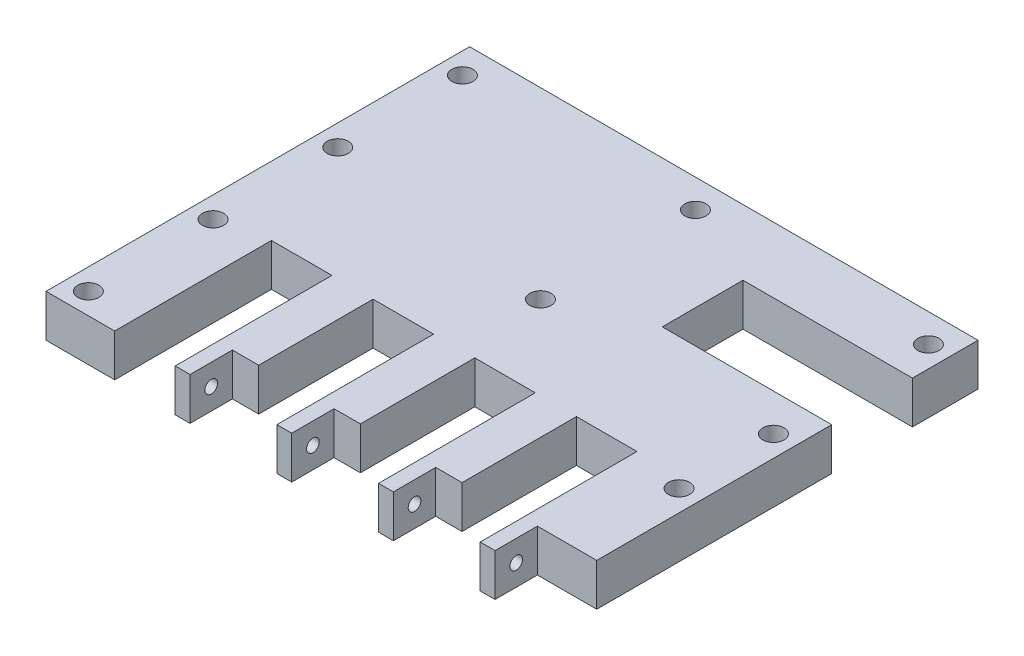
from build123d import *

# Parameters (mm, degrees)
SKETCH1_W                 = 120
SKETCH1_H                 = 100
BOSS_EXTRUDE1_DEPTH       = 10
CUT_EXTRUDE1_DEPTH        = 37
SKETCH3_W                 = 6.2125
SKETCH3_H                 = 10
SKETCH3_W_2               = 14
CUT_EXTRUDE2_DEPTH        = 10
SKETCH4_R                 = 1.5
CUT_EXTRUDE3_DEPTH        = 75.5
SKETCH7_R                 = 2.5
SKETCH7_W                 = 40
SKETCH7_H                 = 19.05
CUT_EXTRUDE4_DEPTH        = 20
SKETCH10_R                = 2.5
CUT_EXTRUDE5_DEPTH        = 10
F_5_0MM_DOWEL_HOLE1_D     = 5
F_5_0MM_DOWEL_HOLE1_DEPTH = 25
F_5_0MM_DOWEL_HOLE1_TIP   = 1.502151548


with BuildPart() as part:
    # Sketch1 → Boss-Extrude1 (new body)
    with BuildSketch(Plane(origin=(0, 0, 0), x_dir=(1, 0, 0), z_dir=(0, 1, 0))):
        Rectangle(SKETCH1_W, SKETCH1_H)
    extrude(amount=BOSS_EXTRUDE1_DEPTH)

    # Sketch2 → Cut-Extrude1 (cut)
    with BuildSketch(Plane.XY.offset(50)):
        Polygon((-42.5, 10), (-43.7875, 10), (-43.7875, -10), (-42.5, -10), (-29.5, -10), (-29.5, 10), align=None)
        Polygon((-5.5, -10), (-18.5, -10), (-19.7875, -10), (-19.7875, 10), (-18.5, 10), (-5.5, 10), align=None)
        Polygon((18.5, -10), (5.5, -10), (4.2125, -10), (4.2125, 10), (5.5, 10), (18.5, 10), align=None)
        Polygon((42.5, -10), (29.5, -10), (28.2125, -10), (28.2125, 10), (29.5, 10), (42.5, 10), align=None)
    extrude(amount=-CUT_EXTRUDE1_DEPTH, mode=Mode.SUBTRACT)

    # Sketch3 → Cut-Extrude2 (cut)
    with BuildSketch(Plane.XY.offset(50)):
        with Locations((-22.89375, 5)):
            Rectangle(SKETCH3_W, SKETCH3_H)
        with Locations((1.10625, 5)):
            Rectangle(SKETCH3_W, SKETCH3_H)
        with Locations((25.10625, 5)):
            Rectangle(SKETCH3_W, SKETCH3_H)
        with Locations((53, 5)):
            Rectangle(SKETCH3_W_2, SKETCH3_H)
    extrude(amount=-CUT_EXTRUDE2_DEPTH, mode=Mode.SUBTRACT)

    # Sketch4 → Cut-Extrude3 (cut)
    with BuildSketch(Plane(origin=(46, 0, 0), x_dir=(0, 0, -1), z_dir=(1, 0, 0))):
        with Locations((-45, 5)):
            Circle(SKETCH4_R)
    extrude(amount=-CUT_EXTRUDE3_DEPTH, mode=Mode.SUBTRACT)

    # Sketch7 → Cut-Extrude4 (cut)
    with BuildSketch(Plane(origin=(0, 10, 0), x_dir=(1, 0, 0), z_dir=(0, 1, 0))):
        with Locations((55, 6.7125)):
            Circle(SKETCH7_R)
        with Locations((55, 43.2875)):
            Circle(SKETCH7_R)
        with Locations((0, 43.2875)):
            Circle(SKETCH7_R)
        with Locations((0, 6.7125)):
            Circle(SKETCH7_R)
        with Locations((40, 25)):
            Rectangle(SKETCH7_W, SKETCH7_H)
    extrude(amount=-CUT_EXTRUDE4_DEPTH, mode=Mode.SUBTRACT)

    # Sketch10 → Cut-Extrude5 (cut)
    with BuildSketch(Plane(origin=(0, 10, 0), x_dir=(1, 0, 0), z_dir=(0, 1, 0))):
        with Locations((-55, 43.2875)):
            Circle(SKETCH10_R)
        with Locations((55, 43.2875)):
            Circle(SKETCH10_R)
        with Locations((55, 6.7125)):
            Circle(SKETCH10_R)
        with Locations((-55, 13.858333333)):
            Circle(SKETCH10_R)
        with Locations((-55, -15.570833333)):
            Circle(SKETCH10_R)
        with Locations((-55, -45)):
            Circle(SKETCH10_R)
        with Locations((55, -15.570833333)):
            Circle(SKETCH10_R)
    extrude(amount=-CUT_EXTRUDE5_DEPTH, mode=Mode.SUBTRACT)

    # Ø5.0mm Dowel Hole1
    with Locations(Plane(origin=(-676.293536786, 10, -1303.282701689), x_dir=(1, 0, 0), z_dir=(0, 1, 0))):
        with Locations((731.293536786, -1318.853535022), (621.293536786, -1318.853535022), (621.293536786, -1348.282701689), (621.293536786, -1259.995201689), (731.293536786, -1259.995201689), (731.293536786, -1296.570201689), (621.293536786, -1289.424368355)):
            Hole(F_5_0MM_DOWEL_HOLE1_D / 2, depth=F_5_0MM_DOWEL_HOLE1_DEPTH)
            with Locations((0, 0, -(F_5_0MM_DOWEL_HOLE1_DEPTH + F_5_0MM_DOWEL_HOLE1_TIP / 2))):  # 118° drill point
                Cone(0, F_5_0MM_DOWEL_HOLE1_D / 2, F_5_0MM_DOWEL_HOLE1_TIP, mode=Mode.SUBTRACT)


solid = part.part
